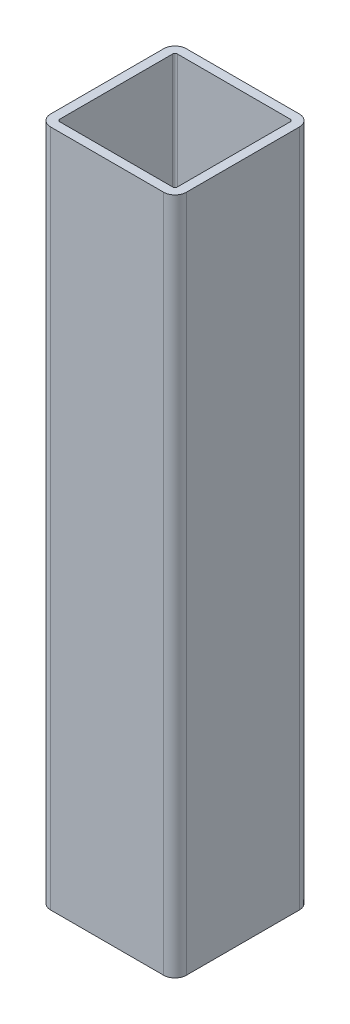
from build123d import *

# Parameters (mm, degrees)
EXTRUDE_THIN1_DEPTH = 95.25


with BuildPart() as part:
    # Sketch1 → Extrude-Thin1 (new body, symmetric)
    with BuildSketch(Plane(origin=(0, 0, 0), x_dir=(1, 0, 0), z_dir=(0, 1, 0))):
        with BuildLine():
            Line((-15.875, 19.05), (15.875, 19.05))
            ThreePointArc((15.875, 19.05), (18.12006403, 18.12006403), (19.05, 15.875))
            Line((19.05, 15.875), (19.05, -15.875))
            ThreePointArc((19.05, -15.875), (18.12006403, -18.12006403), (15.875, -19.05))
            Line((15.875, -19.05), (-15.875, -19.05))
            ThreePointArc((-15.875, -19.05), (-18.12006403, -18.12006403), (-19.05, -15.875))
            Line((-19.05, -15.875), (-19.05, 15.875))
            ThreePointArc((-19.05, 15.875), (-18.12006403, 18.12006403), (-15.875, 19.05))
        make_face()
        with BuildLine():
            Line((-15.875, 16.51), (15.875, 16.51))
            ThreePointArc((15.875, 16.51), (16.324012806, 16.324012806), (16.51, 15.875))
            Line((16.51, 15.875), (16.51, -15.875))
            ThreePointArc((16.51, -15.875), (16.324012806, -16.324012806), (15.875, -16.51))
            Line((15.875, -16.51), (-15.875, -16.51))
            ThreePointArc((-15.875, -16.51), (-16.324012806, -16.324012806), (-16.51, -15.875))
            Line((-16.51, -15.875), (-16.51, 15.875))
            ThreePointArc((-16.51, 15.875), (-16.324012806, 16.324012806), (-15.875, 16.51))
        make_face(mode=Mode.SUBTRACT)
    extrude(amount=EXTRUDE_THIN1_DEPTH, both=True)


solid = part.part
